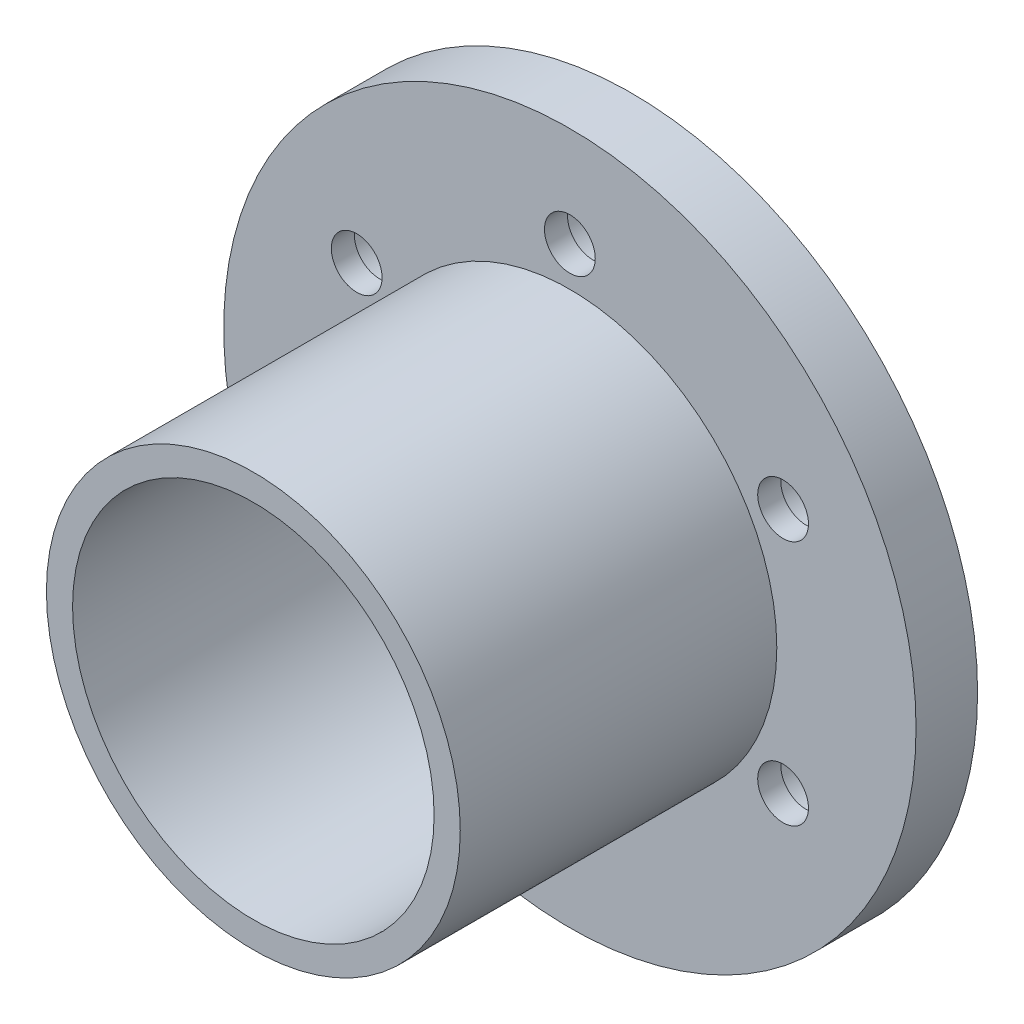
from build123d import *

# Parameters (mm, degrees)
SKETCH2_R                               = 45
BOSS_EXTRUDE1_DEPTH                     = 8
SKETCH5_R                               = 23.5
CUT_EXTRUDE1_DEPTH                      = 9
SKETCH6_R                               = 26.9
BOSS_EXTRUDE2_DEPTH                     = 41.148
SKETCH7_R                               = 23.5
CUT_EXTRUDE3_DEPTH                      = 50.148
CBORE_FOR_M8_HEX_HEAD_BOLT1_D           = 6.6
CBORE_FOR_M8_HEX_HEAD_BOLT1_CBORE_D     = 10
CBORE_FOR_M8_HEX_HEAD_BOLT1_CBORE_DEPTH = 5
CIRPATTERN1_COUNT                       = 6


with BuildPart() as part:
    # Sketch2 → Boss-Extrude1 (new body)
    with BuildSketch(Plane.XY):
        Circle(SKETCH2_R)
    extrude(amount=BOSS_EXTRUDE1_DEPTH)

    # Sketch5 → Cut-Extrude1 (cut, through all)
    with BuildSketch(Plane.XY.offset(8)):
        Circle(SKETCH5_R)
    extrude(amount=-CUT_EXTRUDE1_DEPTH, mode=Mode.SUBTRACT)

    # Sketch6 → Boss-Extrude2 (add)
    with BuildSketch(Plane.XY.offset(8)):
        Circle(SKETCH6_R)
    extrude(amount=BOSS_EXTRUDE2_DEPTH)

    # Sketch7 → Cut-Extrude3 (cut, through all)
    with BuildSketch(Plane.XY.offset(49.148)):
        Circle(SKETCH7_R)
    extrude(amount=-CUT_EXTRUDE3_DEPTH, mode=Mode.SUBTRACT)

    # CBORE for M8 Hex Head Bolt1 (through all)
    with Locations(Plane(origin=(0, 32, 0), x_dir=(-1, 0, 0), z_dir=(0, 0, -1))):
        with Locations((0, 0)):
            cbore_for_m8_hex_head_bolt1 = CounterBoreHole(CBORE_FOR_M8_HEX_HEAD_BOLT1_D / 2, CBORE_FOR_M8_HEX_HEAD_BOLT1_CBORE_D / 2, CBORE_FOR_M8_HEX_HEAD_BOLT1_CBORE_DEPTH)

    # CirPattern1: CBORE for M8 Hex Head Bolt1 ×6 about axis
    cirpattern1_axis = Axis((0, 0, 0), (0, 0, 1))
    for i in range(1, CIRPATTERN1_COUNT):
        add(cbore_for_m8_hex_head_bolt1.rotate(cirpattern1_axis, i * 360 / CIRPATTERN1_COUNT), mode=Mode.SUBTRACT)


solid = part.part
